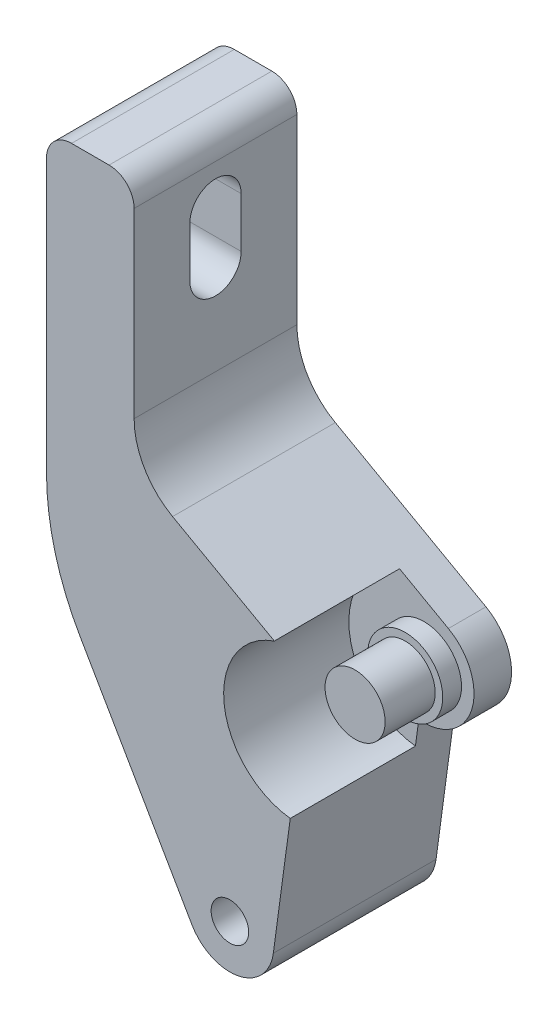
from build123d import *

# Parameters (mm, degrees)
SKETCH1_R           = 1.5
BOSS_EXTRUDE1_DEPTH = 3
SKETCH2_R           = 3
BOSS_EXTRUDE2_DEPTH = 1.5
SKETCH3_R           = 2.4
BOSS_EXTRUDE3_DEPTH = 4
SKETCH4_R           = 1.5
BOSS_EXTRUDE4_DEPTH = 10
FILLET1_R           = 20
FILLET2_R           = 2
CUT_EXTRUDE1_DEPTH  = 25.15


with BuildPart() as part:
    # Sketch1 → Boss-Extrude1 (new body)
    with BuildSketch(Plane.XY):
        with BuildLine():
            Line((-12.031480134, -15.968369445), (-10.412459505, -3.978677815))
            ThreePointArc((-10.412459505, -3.978677815), (-6.186542438, -1.207286803), (-8.04761466, 3.491159046))
            Line((-8.04761466, 3.491159046), (-20.07857801, 10.219318997))
            ThreePointArc((-20.07857801, 10.219318997), (-22.325493603, 12.420556624), (-23.15, 15.456057566))
            Line((-23.15, 15.456057566), (-23.15, 32))
            Line((-23.15, 32), (-30.15, 32))
            Line((-30.15, 32), (-30.15, 2.874544331))
            Line((-30.15, 2.874544331), (-18.531088913, -17.25))
            ThreePointArc((-18.531088913, -17.25), (-14.822887986, -18.933878175), (-12.031480134, -15.968369445))
        make_face()
        with Locations((-15.5, -15.5)):
            Circle(SKETCH1_R, mode=Mode.SUBTRACT)
    extrude(amount=BOSS_EXTRUDE1_DEPTH)

    # Sketch2 → Boss-Extrude2 (add)
    with BuildSketch(Plane.XY.offset(3)):
        with Locations((-10, 0)):
            Circle(SKETCH2_R)
    extrude(amount=BOSS_EXTRUDE2_DEPTH)

    # Sketch3 → Boss-Extrude3 (add)
    with BuildSketch(Plane.XY.offset(4.5)):
        with Locations((-10, 0)):
            Circle(SKETCH3_R)
    extrude(amount=BOSS_EXTRUDE3_DEPTH)

    # Sketch4 → Boss-Extrude4 (add)
    with BuildSketch(Plane.XY.offset(3)):
        with BuildLine():
            Line((-12.031480134, -15.968369445), (-10.680184518, -5.96132108))
            ThreePointArc((-10.680184518, -5.96132108), (-15.964537986, -0.651372866), (-11.950849133, 5.673992215))
            Line((-11.950849133, 5.673992215), (-20.07857801, 10.219318997))
            ThreePointArc((-20.07857801, 10.219318997), (-22.325493603, 12.420556624), (-23.15, 15.456057566))
            Line((-23.15, 15.456057566), (-23.15, 32))
            Line((-23.15, 32), (-30.15, 32))
            Line((-30.15, 32), (-30.15, 2.874544331))
            Line((-30.15, 2.874544331), (-18.531088913, -17.25))
            ThreePointArc((-18.531088913, -17.25), (-14.822887986, -18.933878175), (-12.031480134, -15.968369445))
        make_face()
        with Locations((-15.5, -15.5)):
            Circle(SKETCH4_R, mode=Mode.SUBTRACT)
    extrude(amount=BOSS_EXTRUDE4_DEPTH)

    # Fillet1
    fillet1_edges = [part.edges().sort_by_distance(p)[0] for p in [
        (-30.15, 2.874544331, 6.5),
    ]]
    fillet(fillet1_edges, radius=FILLET1_R)

    # Fillet2
    fillet2_edges = [part.edges().sort_by_distance(p)[0] for p in [
        (-30.15, 32, 6.5),
        (-23.15, 32, 6.5),
    ]]
    fillet(fillet2_edges, radius=FILLET2_R)

    # Sketch5 → Cut-Extrude1 (cut, through all)
    with BuildSketch(Plane.ZY.offset(30.15)):
        with BuildLine():
            Line((8.55, 26.75), (8.55, 22.75))
            ThreePointArc((8.55, 22.75), (6.5, 20.7), (4.45, 22.75))
            Line((4.45, 22.75), (4.45, 26.75))
            ThreePointArc((4.45, 26.75), (6.5, 28.8), (8.55, 26.75))
        make_face()
    extrude(amount=-CUT_EXTRUDE1_DEPTH, mode=Mode.SUBTRACT)


solid = part.part
